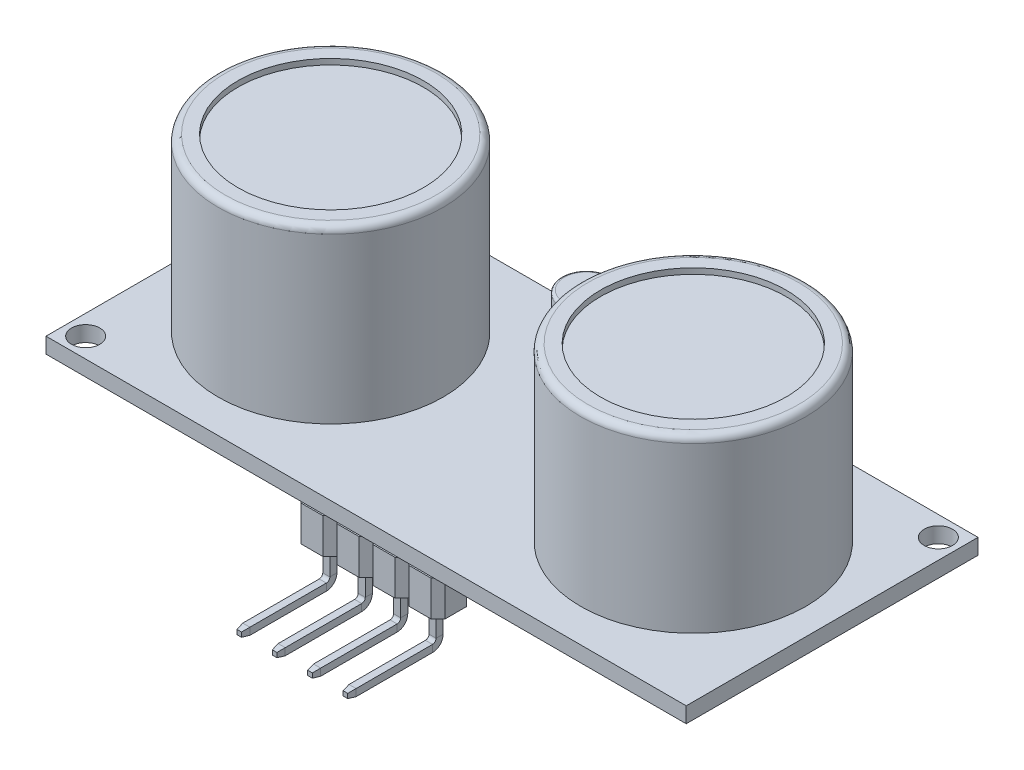
from build123d import *

# Parameters (mm, degrees)
SKETCH1_W            = 45.2
SKETCH1_H            = 20.6
BOSS_EXTRUDE1_DEPTH  = 1.1
SKETCH2_R            = 7.95
BOSS_EXTRUDE2_DEPTH  = 12.1
BOSS_EXTRUDE3_DEPTH  = 2.6
SKETCH5_W            = 10.591964238
SKETCH5_H            = 2.906134497
SKETCH5_W_2          = 9.8
SKETCH5_H_2          = 2.3
CUT_EXTRUDE2_DEPTH   = 0.1
SKETCH6_W            = 0.5
SKETCH6_H            = 0.5
SKETCH8_W            = 0.5
SKETCH8_H            = 0.5
BOSS_EXTRUDE4_DEPTH  = 0.5
BOSS_EXTRUDE4_TAPER  = 10
LPATTERN1_COUNT      = 4
LPATTERN1_PITCH      = 2.5
SKETCH9_R            = 6.55
CUT_EXTRUDE3_DEPTH   = 10
SKETCH10_R           = 5.35
BOSS_EXTRUDE5_DEPTH  = 1
SKETCH11_R           = 3.55
BOSS_EXTRUDE6_DEPTH  = 1
BOSS_EXTRUDE10_DEPTH = 0.7
BOSS_EXTRUDE11_DEPTH = 2.8
SKETCH18_R           = 1
CUT_EXTRUDE4_DEPTH   = 7.45
SKETCH19_R           = 0.5
BOSS_EXTRUDE12_DEPTH = 2.6
CUT_EXTRUDE5_DEPTH   = 0.1
FILLET1_R            = 0.5
SKETCH33_R           = 6.55
BOSS_EXTRUDE21_DEPTH = 0.1
FILLET4_R            = 0.2


with BuildPart() as part:
    # Sketch1 → Boss-Extrude1 (new body)
    with BuildSketch(Plane(origin=(0, 0, 0), x_dir=(1, 0, 0), z_dir=(0, 1, 0))):
        Rectangle(SKETCH1_W, SKETCH1_H)
    extrude(amount=BOSS_EXTRUDE1_DEPTH)

    # Sketch2 → Boss-Extrude2 (add)
    with BuildSketch(Plane(origin=(0, 1.1, 0), x_dir=(1, 0, 0), z_dir=(0, 1, 0))):
        with Locations((12.8, 0)):
            Circle(SKETCH2_R)
        with Locations((-12.8, 0)):
            Circle(SKETCH2_R)
    extrude(amount=BOSS_EXTRUDE2_DEPTH)

    # Sketch3 → Boss-Extrude3 (add)
    with BuildSketch(Plane.XZ):
        Polygon((-4.58, 10.3), (-5.08, 9.8), (-5.08, 8.3), (-4.58, 7.8), (-3.04, 7.8), (-2.54, 8.3), (-2.04, 7.8), (-0.5, 7.8), (0, 8.3), (0.5, 7.8), (2.04, 7.8), (2.54, 8.3), (3.04, 7.8), (4.58, 7.8), (5.08, 8.3), (5.08, 9.8), (4.58, 10.3), (3.04, 10.3), (2.54, 9.8), (2.04, 10.3), (0.5, 10.3), (0, 9.8), (-0.5, 10.3), (-2.04, 10.3), (-2.54, 9.8), (-3.04, 10.3), align=None)
    extrude(amount=BOSS_EXTRUDE3_DEPTH)

    # Sketch5 → Cut-Extrude2 (cut)
    with BuildSketch(Plane.XZ):
        with Locations((0, 9.071641639)):
            Rectangle(SKETCH5_W, SKETCH5_H)
        with Locations((0, 9.05)):
            Rectangle(SKETCH5_W_2, SKETCH5_H_2, mode=Mode.SUBTRACT)
    extrude(amount=CUT_EXTRUDE2_DEPTH, mode=Mode.SUBTRACT)

    # Sweep1: sweep along a path in Sketch7
    with BuildLine(Plane(origin=(-3.81, 0, 0), x_dir=(0, 0, -1), z_dir=(1, 0, 0))) as sweep1_path:
        Line((-9.05, -2.6), (-9.05, -4.6))
        ThreePointArc((-9.05, -4.6), (-9.196446609, -4.953553391), (-9.55, -5.1))
        Line((-9.55, -5.1), (-14.95, -5.1))
    # Sketch6 → Sweep1 (sweep)
    with BuildSketch(Plane.XZ.offset(2.6)):
        with Locations((-3.81, 9.05)):
            Rectangle(SKETCH6_W, SKETCH6_H)
    sweep1 = sweep(path=sweep1_path.line)

    # Sketch8 → Boss-Extrude4 (add)
    with BuildSketch(Plane.XY.offset(14.95)):
        with Locations((-3.81, -5.1)):
            Rectangle(SKETCH8_W, SKETCH8_H)
    boss_extrude4 = extrude(amount=BOSS_EXTRUDE4_DEPTH, taper=BOSS_EXTRUDE4_TAPER)

    # LPattern1: Sweep1, Boss-Extrude4 ×4
    with Locations(*[(i * LPATTERN1_PITCH, 0, 0) for i in range(1, LPATTERN1_COUNT)]):
        add(sweep1)
        add(boss_extrude4)

    # Sketch9 → Cut-Extrude3 (cut)
    with BuildSketch(Plane(origin=(0, 13.2, 0), x_dir=(1, 0, 0), z_dir=(0, 1, 0))):
        with Locations((12.8, 0)):
            Circle(SKETCH9_R)
    cut_extrude3 = extrude(amount=-CUT_EXTRUDE3_DEPTH, mode=Mode.SUBTRACT)

    # Sketch10 → Boss-Extrude5 (add)
    with BuildSketch(Plane(origin=(0, 3.2, 0), x_dir=(1, 0, 0), z_dir=(0, 1, 0))):
        with Locations((12.8, 0)):
            Circle(SKETCH10_R)
    boss_extrude5 = extrude(amount=BOSS_EXTRUDE5_DEPTH)

    # Sketch11 → Boss-Extrude6 (add)
    with BuildSketch(Plane(origin=(0, 4.2, 0), x_dir=(1, 0, 0), z_dir=(0, 1, 0))):
        with Locations((12.8, 0)):
            Circle(SKETCH11_R)
    boss_extrude6 = extrude(amount=BOSS_EXTRUDE6_DEPTH)

    # Mirror1: Cut-Extrude3, Boss-Extrude5, Boss-Extrude6 across plane
    add(cut_extrude3.mirror(Plane(origin=(0, 0, 0), x_dir=(0, 0, 1), z_dir=(1, 0, 0))), mode=Mode.SUBTRACT)
    add(boss_extrude5.mirror(Plane(origin=(0, 0, 0), x_dir=(0, 0, 1), z_dir=(1, 0, 0))))
    add(boss_extrude6.mirror(Plane(origin=(0, 0, 0), x_dir=(0, 0, 1), z_dir=(1, 0, 0))))

    # Sketch16 → Boss-Extrude10 (add)
    with BuildSketch(Plane(origin=(0, 1.1, 0), x_dir=(1, 0, 0), z_dir=(0, 1, 0))):
        with BuildLine():
            Line((-2.85, 10.3), (2.85, 10.3))
            ThreePointArc((2.85, 10.3), (5.05, 8.1), (2.85, 5.9))
            Line((2.85, 5.9), (-2.85, 5.9))
            ThreePointArc((-2.85, 5.9), (-5.05, 8.1), (-2.85, 10.3))
        make_face()
    extrude(amount=BOSS_EXTRUDE10_DEPTH)

    # Sketch17 → Boss-Extrude11 (add)
    with BuildSketch(Plane(origin=(0, 1.8, 0), x_dir=(1, 0, 0), z_dir=(0, 1, 0))):
        with BuildLine():
            Line((-2.85, 9.85), (2.85, 9.85))
            ThreePointArc((2.85, 9.85), (4.6, 8.1), (2.85, 6.35))
            Line((2.85, 6.35), (-2.85, 6.35))
            ThreePointArc((-2.85, 6.35), (-4.6, 8.1), (-2.85, 9.85))
        make_face()
    extrude(amount=BOSS_EXTRUDE11_DEPTH)

    # Sketch18 → Cut-Extrude4 (cut, through all)
    with BuildSketch(Plane(origin=(0, 1.1, 0), x_dir=(1, 0, 0), z_dir=(0, 1, 0))):
        with Locations((-21.2, -8.9)):
            Circle(SKETCH18_R)
        with Locations((21.2, 8.9)):
            Circle(SKETCH18_R)
    extrude(amount=-CUT_EXTRUDE4_DEPTH, mode=Mode.SUBTRACT)

    # Sketch19 → Boss-Extrude12 (add)
    with BuildSketch(Plane.XZ):
        with Locations((-12.8, 4.65)):
            Circle(SKETCH19_R)
        with Locations((-12.8, -4.65)):
            Circle(SKETCH19_R)
        with Locations((12.8, -4.65)):
            Circle(SKETCH19_R)
        with Locations((12.8, 4.65)):
            Circle(SKETCH19_R)
    extrude(amount=BOSS_EXTRUDE12_DEPTH)

    # Sketch20 → Cut-Extrude5 (cut)
    with BuildSketch(Plane(origin=(0, 1.1, 0), x_dir=(1, 0, 0), z_dir=(0, 1, 0))):
        with BuildLine():
            Line((-2.85, 5.9), (2.85, 5.9))
            ThreePointArc((2.85, 5.9), (5.05, 8.1), (2.85, 10.3))
            Line((2.85, 10.3), (-2.85, 10.3))
            ThreePointArc((-2.85, 10.3), (-5.05, 8.1), (-2.85, 5.9))
        make_face()
        with BuildLine():
            Line((-2.85, 6), (2.85, 6))
            ThreePointArc((2.85, 6), (4.95, 8.1), (2.85, 10.2))
            Line((2.85, 10.2), (-2.85, 10.2))
            ThreePointArc((-2.85, 10.2), (-4.95, 8.1), (-2.85, 6))
        make_face(mode=Mode.SUBTRACT)
    extrude(amount=CUT_EXTRUDE5_DEPTH, mode=Mode.SUBTRACT)

    # Fillet1
    fillet1_edges = [part.edges().sort_by_distance(p)[0] for p in [
        (4.85, 13.2, 0),
        (-20.75, 13.2, 0),
    ]]
    fillet(fillet1_edges, radius=FILLET1_R)

    # Sketch33 → Boss-Extrude21 (add)
    with BuildSketch(Plane(origin=(0, 12.7, 0), x_dir=(1, 0, 0), z_dir=(0, 1, 0))):
        with Locations((12.8, 0)):
            Circle(SKETCH33_R)
    boss_extrude21 = extrude(amount=BOSS_EXTRUDE21_DEPTH)

    # Mirror2: Boss-Extrude21 across plane
    add(boss_extrude21.mirror(Plane(origin=(0, 0, 0), x_dir=(0, 0, 1), z_dir=(1, 0, 0))))

    # Fillet4
    fillet4_edges = [part.edges().sort_by_distance(p)[0] for p in [
        (-4.6, 1.8, -8.1),
        (0, 1.8, -6.35),
        (4.6, 1.8, -8.1),
        (0, 1.8, -9.85),
        (-4.6, 4.6, -8.1),
        (0, 4.6, -6.35),
        (4.6, 4.6, -8.1),
        (0, 4.6, -9.85),
    ]]
    fillet(fillet4_edges, radius=FILLET4_R)


solid = part.part
